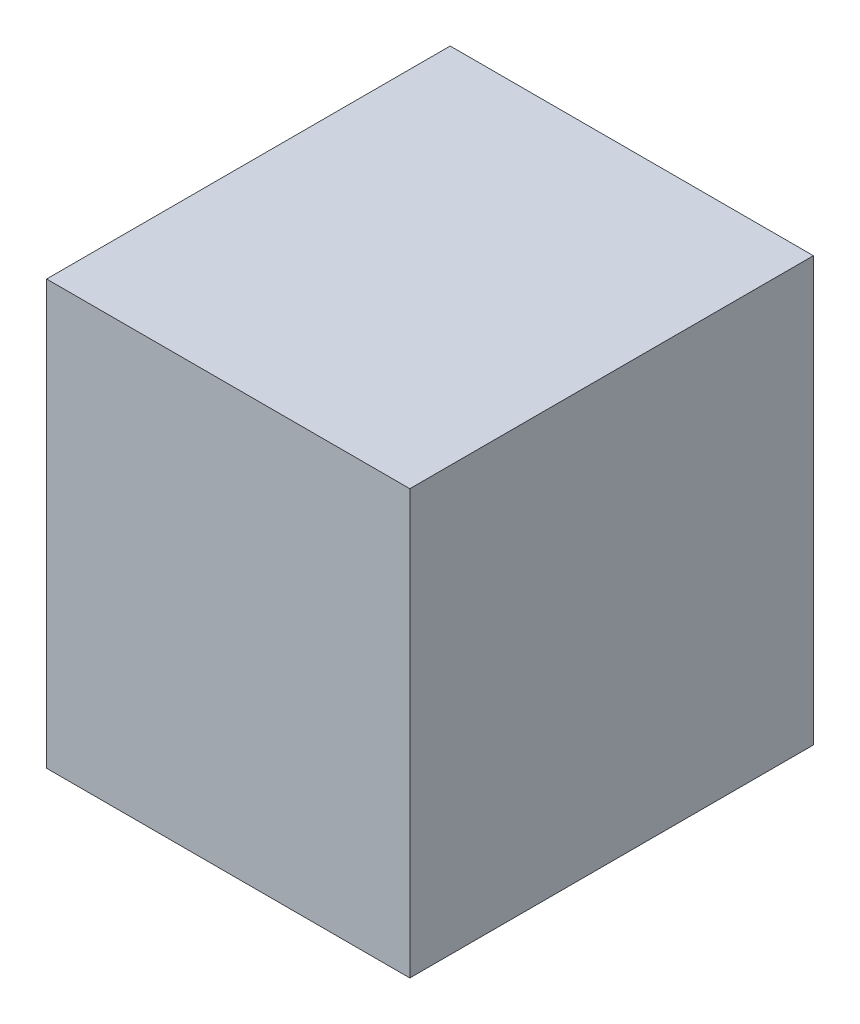
from build123d import *

# Parameters (mm, degrees)
SKETCH1_W           = 228.6
SKETCH1_H           = 254
BOSS_EXTRUDE1_DEPTH = 266.7


with BuildPart() as part:
    # Sketch1 → Boss-Extrude1 (new body)
    with BuildSketch(Plane(origin=(0, 0, 0), x_dir=(1, 0, 0), z_dir=(0, 1, 0))):
        with Locations((-41.148, -85.852)):
            Rectangle(SKETCH1_W, SKETCH1_H)
    extrude(amount=BOSS_EXTRUDE1_DEPTH)


solid = part.part
